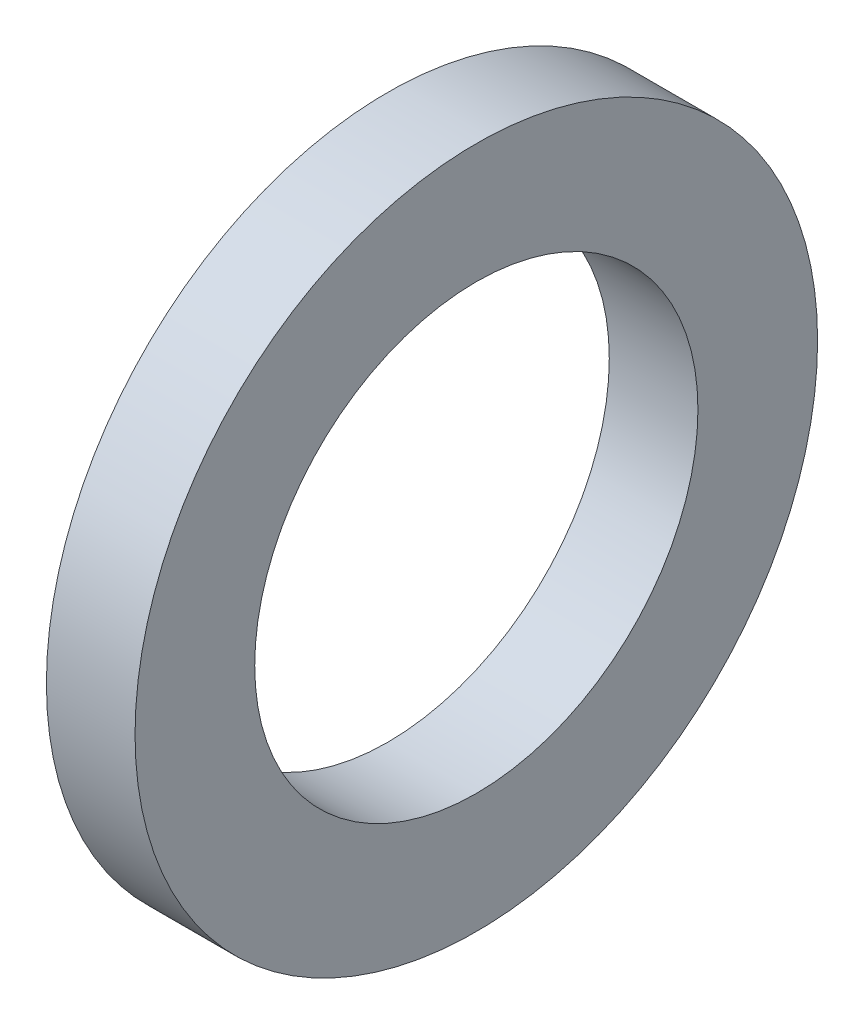
from build123d import *

# Parameters (mm, degrees)
SKETCH1_W = 1
SKETCH1_H = 1.35


with BuildPart() as part:
    # Sketch1 → Revolve1 (revolve)
    with BuildSketch(Plane.XY):
        with Locations((0, 3.175)):
            Rectangle(SKETCH1_W, SKETCH1_H)
    revolve(axis=Axis((0, 0, 0), (1, 0, 0)))


solid = part.part
